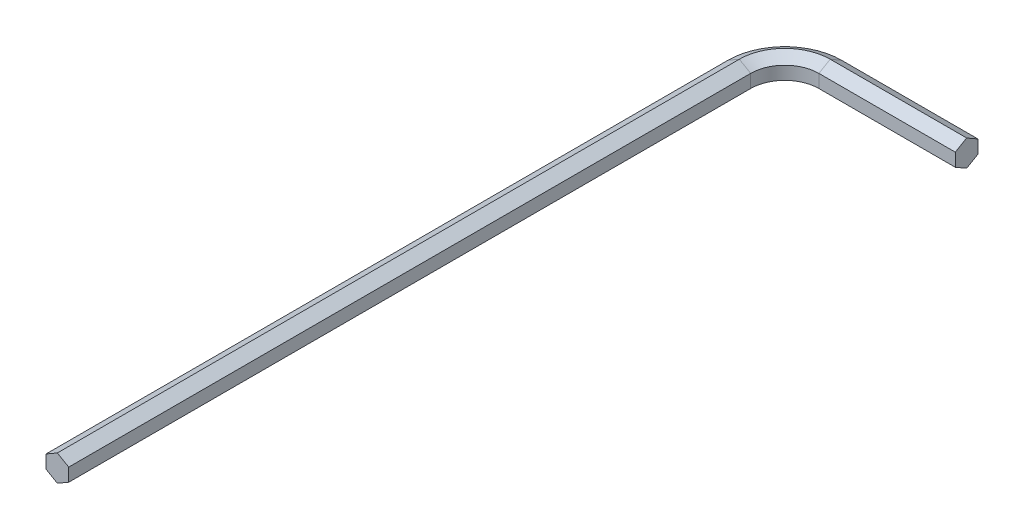
from build123d import *


with BuildPart() as part:
    # Sweep1: sweep along a path in Sketch2
    with BuildLine(Plane(origin=(0, 0, 0), x_dir=(1, 0, 0), z_dir=(0, 1, 0))) as sweep1_path:
        Line((0, 0), (0, 75))
        ThreePointArc((0, 75), (1.464466094, 78.535533906), (5, 80))
        Line((5, 80), (20, 80))
    # Sketch1 → Sweep1 (sweep)
    with BuildSketch(Plane.XY):
        Polygon((-1.25, 0.721687836), (-1.25, -0.721687836), (0, -1.443375673), (1.25, -0.721687836), (1.25, 0.721687836), (0, 1.443375673), align=None)
    sweep(path=sweep1_path.line)


solid = part.part
